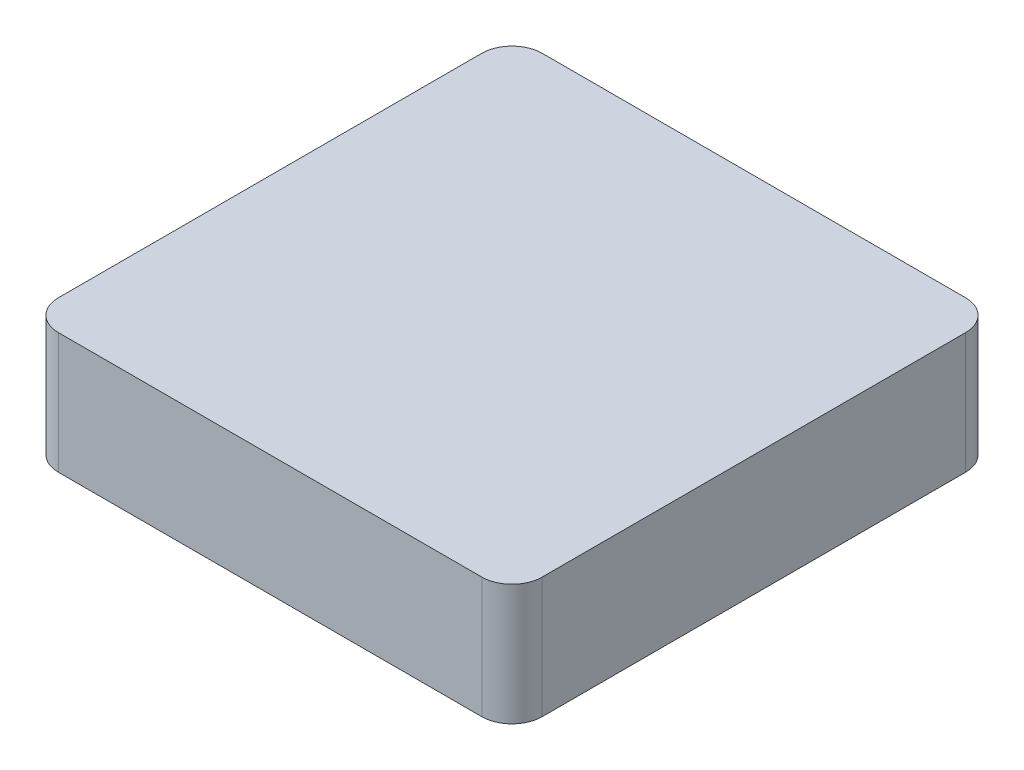
from build123d import *

# Parameters (mm, degrees)
ESQUISSE1_W      = 80
ESQUISSE1_H      = 80
EXTRUSION1_DEPTH = 20
CONG_1_R         = 5
COQUE1_T         = -2


with BuildPart() as part:
    # Esquisse1 → Extrusion1 (new body)
    with BuildSketch(Plane(origin=(0, 0, 0), x_dir=(1, 0, 0), z_dir=(0, 1, 0))):
        with Locations((40, 40)):
            Rectangle(ESQUISSE1_W, ESQUISSE1_H)
    extrude(amount=EXTRUSION1_DEPTH)

    # Congé1
    cong_1_edges = [part.edges().sort_by_distance(p)[0] for p in [
        (0, 10, -80),
        (80, 10, -80),
        (80, 10, 0),
        (0, 10, 0),
    ]]
    fillet(cong_1_edges, radius=CONG_1_R)

    # Coque1
    coque1_openings = [part.faces().sort_by_distance(p)[0] for p in [
        (40, 0, -40),
    ]]
    offset(amount=COQUE1_T, openings=coque1_openings, kind=Kind.INTERSECTION)


solid = part.part
